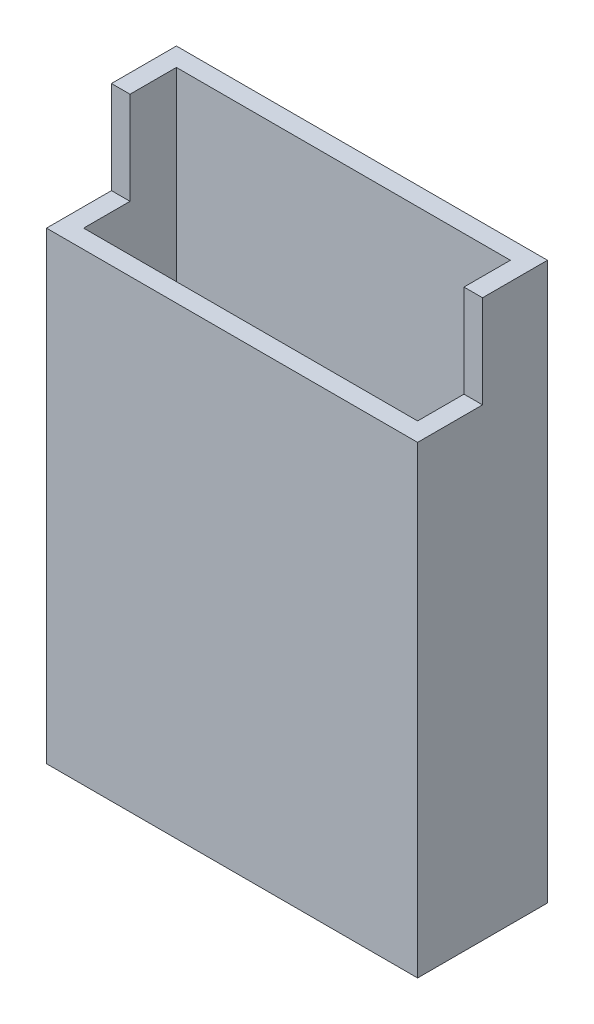
from build123d import *

# Parameters (mm, degrees)
SKETCH_1_W          = 40
SKETCH_1_H          = 14
EXTRUDE_1_DEPTH     = 60
SKETCH_6_W          = 36
SKETCH_6_H          = 10
CUT_EXTRUDE_2_DEPTH = 55
SKETCH_7_W          = 40
SKETCH_7_H          = 10
CUT_EXTRUDE_3_DEPTH = 7


with BuildPart() as part:
    # 草图1 → 凸台-拉伸1 (new body)
    with BuildSketch(Plane(origin=(0, 0, 0), x_dir=(1, 0, 0), z_dir=(0, 1, 0))):
        with Locations((20, 7)):
            Rectangle(SKETCH_1_W, SKETCH_1_H)
    extrude(amount=EXTRUDE_1_DEPTH)

    # 草图6 → 切除-拉伸2 (cut)
    with BuildSketch(Plane(origin=(0, 60, 0), x_dir=(1, 0, 0), z_dir=(0, 1, 0))):
        with Locations((20, 7)):
            Rectangle(SKETCH_6_W, SKETCH_6_H)
    extrude(amount=-CUT_EXTRUDE_2_DEPTH, mode=Mode.SUBTRACT)

    # 草图7 → 切除-拉伸3 (cut)
    with BuildSketch(Plane.XY):
        with Locations((20, 55)):
            Rectangle(SKETCH_7_W, SKETCH_7_H)
    extrude(amount=-CUT_EXTRUDE_3_DEPTH, mode=Mode.SUBTRACT)


solid = part.part
